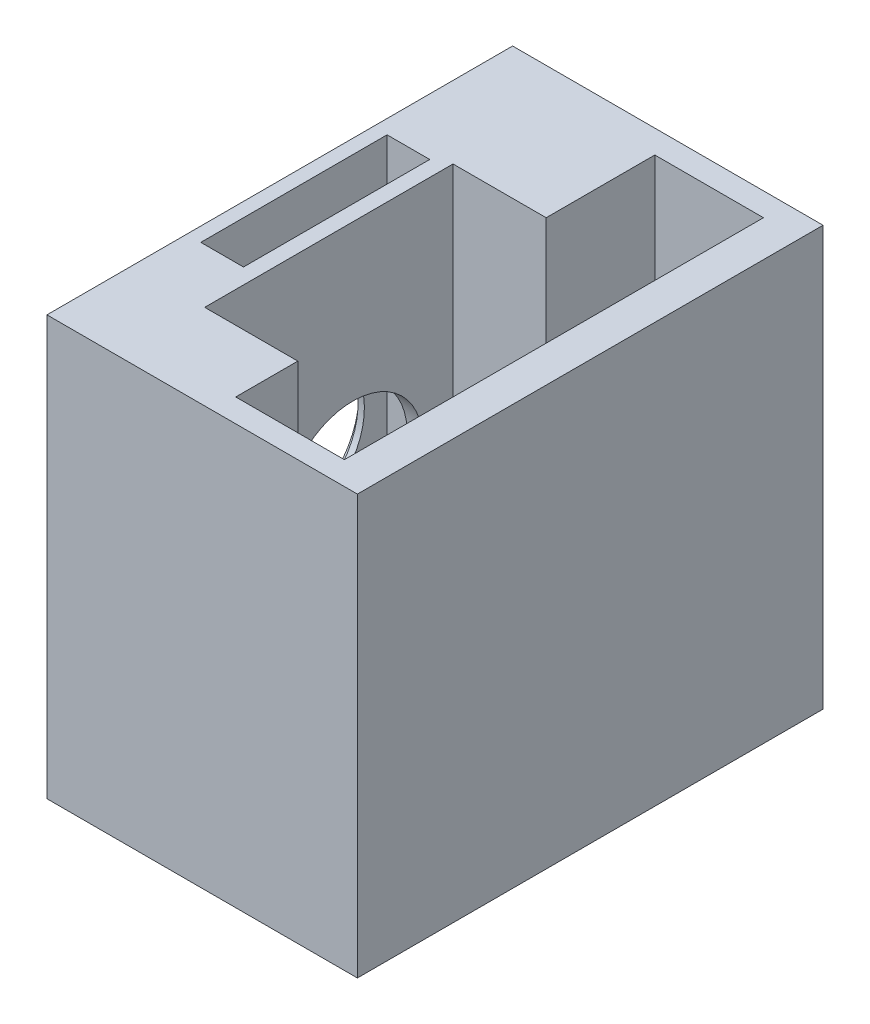
from build123d import *

# Parameters (mm, degrees)
SKETCH2_W           = 30
SKETCH2_H           = 27
BOSS_EXTRUDE1_DEPTH = 20
SKETCH6_W           = 7
SKETCH6_H           = 27
CUT_EXTRUDE4_DEPTH  = 26
SKETCH9_W           = 6
SKETCH9_H           = 16
CUT_EXTRUDE5_DEPTH  = 21
SKETCH11_R          = 5
CUT_EXTRUDE8_DEPTH  = 0.5
SKETCH12_W          = 2.75
SKETCH12_H          = 12
CUT_EXTRUDE12_DEPTH = 17.5
SKETCH15_R          = 4.5
CUT_EXTRUDE13_DEPTH = 5


with BuildPart() as part:
    # Sketch2 → Boss-Extrude1 (new body)
    with BuildSketch(Plane(origin=(0, 0, 0), x_dir=(0, 0, -1), z_dir=(1, 0, 0))):
        with Locations((15, 13.5)):
            Rectangle(SKETCH2_W, SKETCH2_H)
    extrude(amount=BOSS_EXTRUDE1_DEPTH)

    # Sketch6 → Cut-Extrude4 (cut)
    with BuildSketch(Plane(origin=(2.296116437, 27, -0.293484995), x_dir=(1, 0, 0), z_dir=(0, 1, 0))):
        with Locations((11.865844825, 14.706515005)):
            Rectangle(SKETCH6_W, SKETCH6_H)
    extrude(amount=-CUT_EXTRUDE4_DEPTH, mode=Mode.SUBTRACT)

    # Sketch9 → Cut-Extrude5 (cut)
    with BuildSketch(Plane(origin=(0, 27, 0), x_dir=(1, 0, 0), z_dir=(0, 1, 0))):
        with Locations((7.661961261, 13.5)):
            Rectangle(SKETCH9_W, SKETCH9_H)
    extrude(amount=-CUT_EXTRUDE5_DEPTH, mode=Mode.SUBTRACT)

    # Sketch11 → Cut-Extrude8 (cut)
    with BuildSketch(Plane.ZY):
        with Locations((-15.1, 12.5)):
            Circle(SKETCH11_R)
    extrude(amount=-CUT_EXTRUDE8_DEPTH, mode=Mode.SUBTRACT)

    # Sketch12 → Cut-Extrude12 (cut)
    with BuildSketch(Plane(origin=(0, 27, 0), x_dir=(1, 0, 0), z_dir=(0, 1, 0))):
        with Locations((2.286961261, 15)):
            Rectangle(SKETCH12_W, SKETCH12_H)
    extrude(amount=-CUT_EXTRUDE12_DEPTH, mode=Mode.SUBTRACT)

    # Sketch15 → Cut-Extrude13 (cut)
    with BuildSketch(Plane.ZY.offset(-0.5)):
        with Locations((-15.04, 12.5)):
            Circle(SKETCH15_R)
    extrude(amount=-CUT_EXTRUDE13_DEPTH, mode=Mode.SUBTRACT)


solid = part.part
